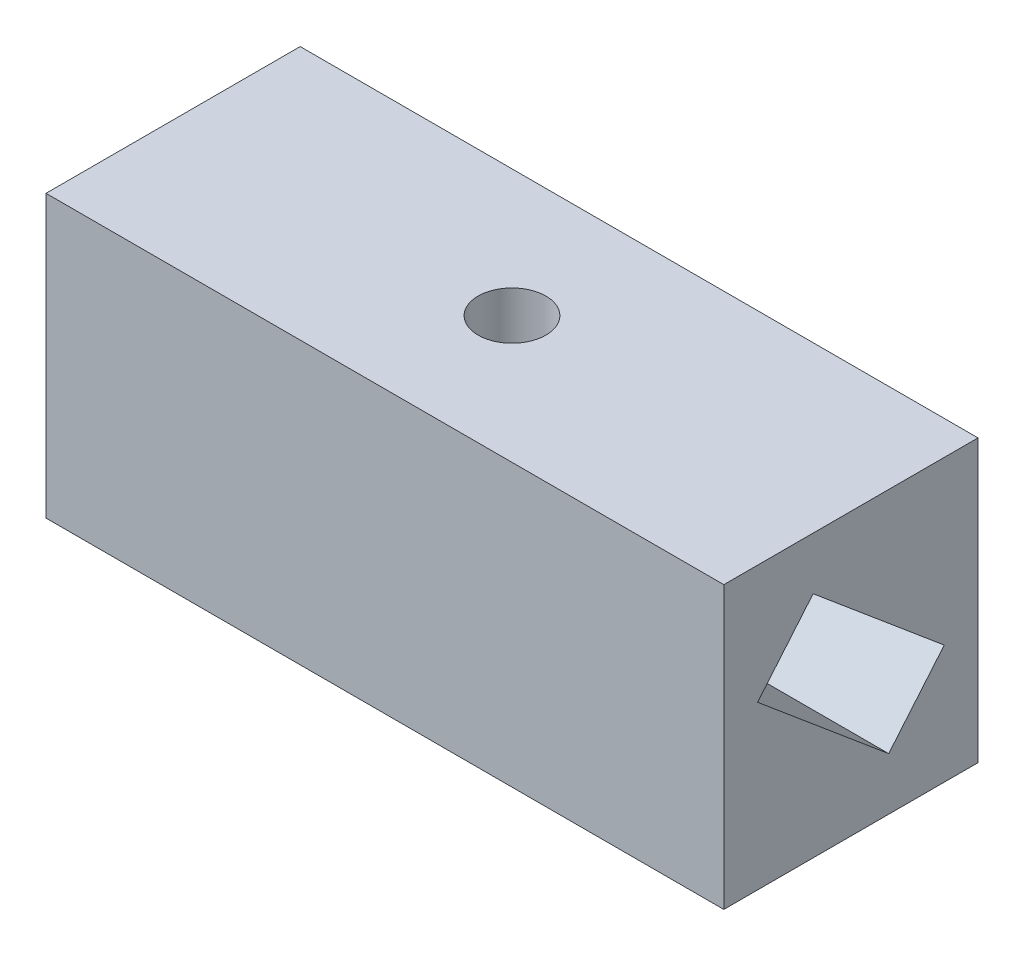
from build123d import *

# Parameters (mm, degrees)
SKETCH_1_W          = 80
SKETCH_1_H          = 30
EXTRUDE_1_DEPTH     = 33.2
SKETCH_2_R          = 4
CUT_EXTRUDE_1_DEPTH = 34.2
CUT_EXTRUDE_4_DEPTH = 30
CUT_EXTRUDE_5_DEPTH = 30


with BuildPart() as part:
    # Эскиз1 → Бобышка-Вытянуть1 (new body)
    with BuildSketch(Plane(origin=(0, 0, 0), x_dir=(1, 0, 0), z_dir=(0, 1, 0))):
        Rectangle(SKETCH_1_W, SKETCH_1_H)
    extrude(amount=EXTRUDE_1_DEPTH)

    # Эскиз2 → Вырез-Вытянуть1 (cut, through all)
    with BuildSketch(Plane(origin=(0, 33.2, 0), x_dir=(1, 0, 0), z_dir=(0, 1, 0))):
        with Locations(Location((0, 0, 0), (0, 0, 270))):  # turned: the seam where the file's is
            Circle(SKETCH_2_R)
    extrude(amount=-CUT_EXTRUDE_1_DEPTH, mode=Mode.SUBTRACT)

    # Эскиз5 → Вырез-Вытянуть4 (cut)
    with BuildSketch(Plane.ZY.offset(40)):
        Polygon((-11.015265685, 14.014671802), (-4.458832066, 6.201018482), (11.015265685, 19.185328198), (4.458832066, 26.998981518), align=None)
    extrude(amount=-CUT_EXTRUDE_4_DEPTH, mode=Mode.SUBTRACT)

    # Эскиз6 → Вырез-Вытянуть5 (cut)
    with BuildSketch(Plane(origin=(40, 0, 0), x_dir=(0, 0, -1), z_dir=(1, 0, 0))):
        Polygon((11.015265685, 14.014671802), (4.458832066, 6.201018482), (-11.015265685, 19.185328198), (-4.458832066, 26.998981518), align=None)
    extrude(amount=-CUT_EXTRUDE_5_DEPTH, mode=Mode.SUBTRACT)


solid = part.part
